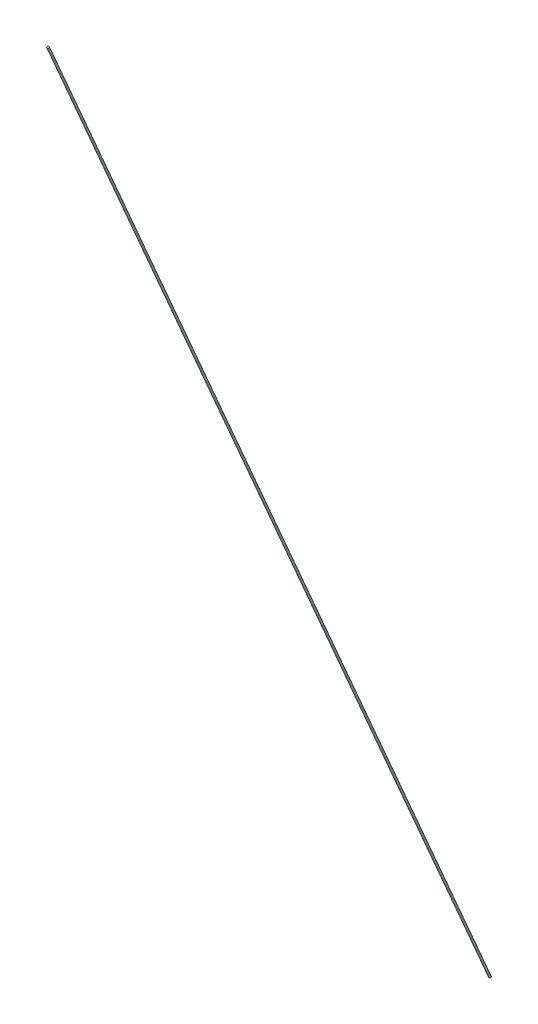
from build123d import *

# Parameters (mm, degrees)
SWEEP_1_PROFILE_R = 0.5


with BuildPart() as part:
    # 扫描1: sweep along a path in 草图3
    with BuildLine(Plane(origin=(0, 0, 0), x_dir=(0, 0, -1), z_dir=(1, 0, 0))) as sweep_1_path:
        Line((0, 0), (-217.5, 505))
    # 扫描1 profile (on start of the path) → 扫描1 (sweep)
    with BuildSketch(Plane(origin=(0, 0, 0), x_dir=(0, -0.395564894, 0.91843803), z_dir=(0, 0.91843803, 0.395564894))):
        Circle(SWEEP_1_PROFILE_R)
    sweep(path=sweep_1_path.line)


solid = part.part
